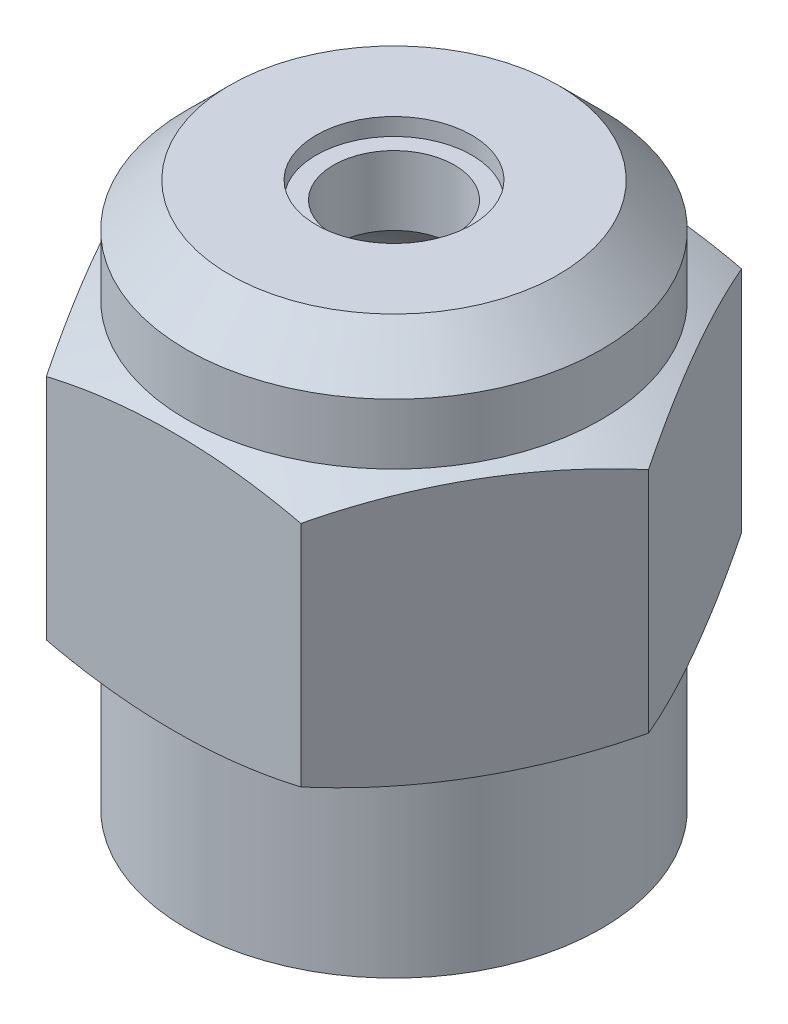
from build123d import *

# Parameters (mm, degrees)
SKETCH3_R           = 6.096
BOSS_EXTRUDE1_DEPTH = 7.874


with BuildPart() as part:
    # Sketch1 → Base-Revolve (revolve)
    with BuildSketch(Plane.XY):
        with BuildLine():
            Line((6.096, 0), (6.096, 14.732))
            Line((6.096, 14.732), (4.826, 16.002))
            Line((4.826, 16.002), (2.286, 16.002))
            Line((2.286, 16.002), (2.286, 15.494))
            Line((2.286, 15.494), (1.778, 15.494))
            Line((1.778, 15.494), (1.778, 13.462))
            ThreePointArc((1.778, 13.462), (3.53667068, 11.915498853), (4.191, 9.666845589))
            Line((4.191, 9.666845589), (4.191, 0))
            Line((4.191, 0), (6.096, 0))
        make_face()
    revolve(axis=Axis((0, 0, 0), (0, 1, 0)))

    # Sketch3 → Boss-Extrude1 (add)
    with BuildSketch(Plane(origin=(0, 12.954, 0), x_dir=(-1, 0, 0), z_dir=(0, 1, 0))):
        Polygon((3.739497694, -6.477), (-3.739497694, -6.477), (-7.478995387, 0), (-3.739497694, 6.477), (3.739497694, 6.477), (7.478995387, 0), align=None)
        Circle(SKETCH3_R, mode=Mode.SUBTRACT)
    extrude(amount=-BOSS_EXTRUDE1_DEPTH)

    # Sketch4 → Cut-Revolve1 (revolve, cut)
    with BuildSketch(Plane.XY):
        with BuildLine():
            Line((7.478995387, 12.954), (6.096, 12.954))
            ThreePointArc((6.096, 12.954), (6.793780049, 12.676772421), (7.478995387, 12.3698))
            Line((7.478995387, 12.3698), (7.478995387, 12.954))
        make_face()
    cut_revolve1 = revolve(axis=Axis((0, 0, 0), (0, 1, 0)), mode=Mode.SUBTRACT)

    # Mirror1: Cut-Revolve1 across plane
    add(cut_revolve1.mirror(Plane.ZX.offset(9.017)), mode=Mode.SUBTRACT)


solid = part.part
